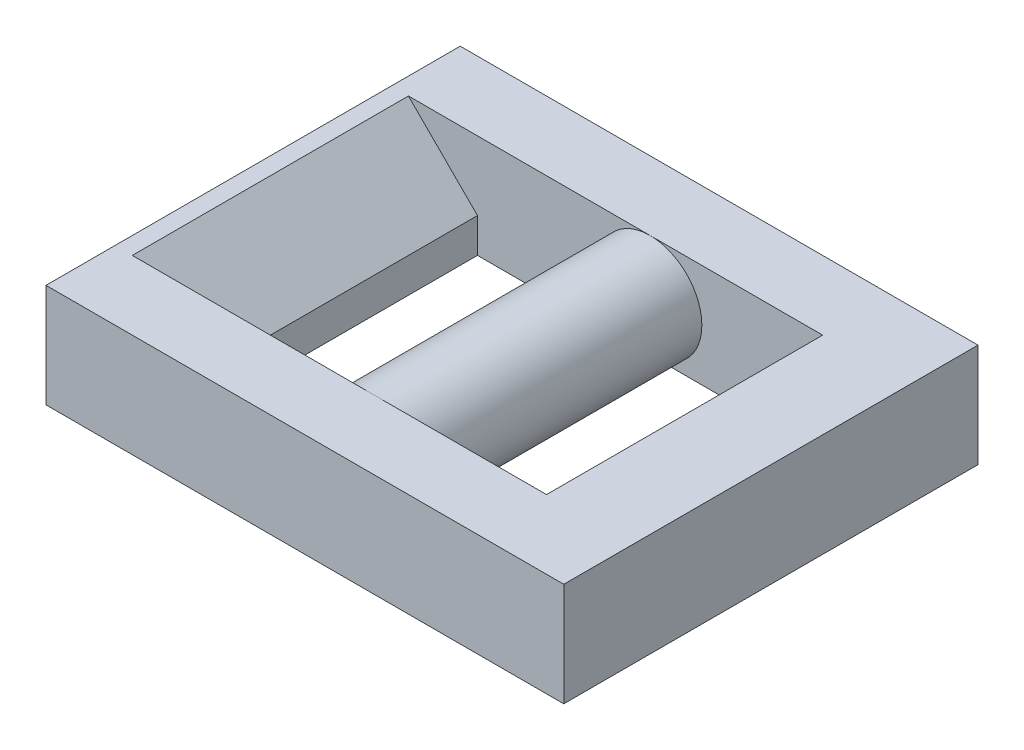
from build123d import *

# Parameters (mm, degrees)
SKETCH1_W           = 15
SKETCH1_H           = 12
SKETCH1_W_2         = 10
SKETCH1_H_2         = 8
BOSS_EXTRUDE1_DEPTH = 1.5
BOSS_EXTRUDE2_REACH = 12
SKETCH2_R           = 1.5
CHAMFER1_SIZE       = 2
CHAMFER2_SIZE       = 2


with BuildPart() as part:
    # Sketch1 → Boss-Extrude1 (new body, symmetric)
    with BuildSketch(Plane(origin=(0, 0, 0), x_dir=(1, 0, 0), z_dir=(0, 1, 0))):
        Rectangle(SKETCH1_W, SKETCH1_H)
        Rectangle(SKETCH1_W_2, SKETCH1_H_2, mode=Mode.SUBTRACT)
    extrude(amount=BOSS_EXTRUDE1_DEPTH, both=True)

    # Sketch2 → Boss-Extrude2 (add, up to next)
    with BuildSketch(Plane.XY.offset(-4), mode=Mode.PRIVATE) as boss_extrude2_sk1:
        Circle(SKETCH2_R)
    boss_extrude2_tool1 = extrude(boss_extrude2_sk1.sketch, amount=BOSS_EXTRUDE2_REACH, mode=Mode.PRIVATE) - part.part
    add(boss_extrude2_tool1.solids().sort_by_distance((0, 0, -4))[0])

    # Chamfer1
    chamfer1_edges = [part.edges().sort_by_distance(p)[0] for p in [
        (5, -1.5, 0),
    ]]
    chamfer(chamfer1_edges, length=CHAMFER1_SIZE)

    # Chamfer2
    chamfer2_edges = [part.edges().sort_by_distance(p)[0] for p in [
        (-5, 1.5, 0),
    ]]
    chamfer(chamfer2_edges, length=CHAMFER2_SIZE)


solid = part.part
